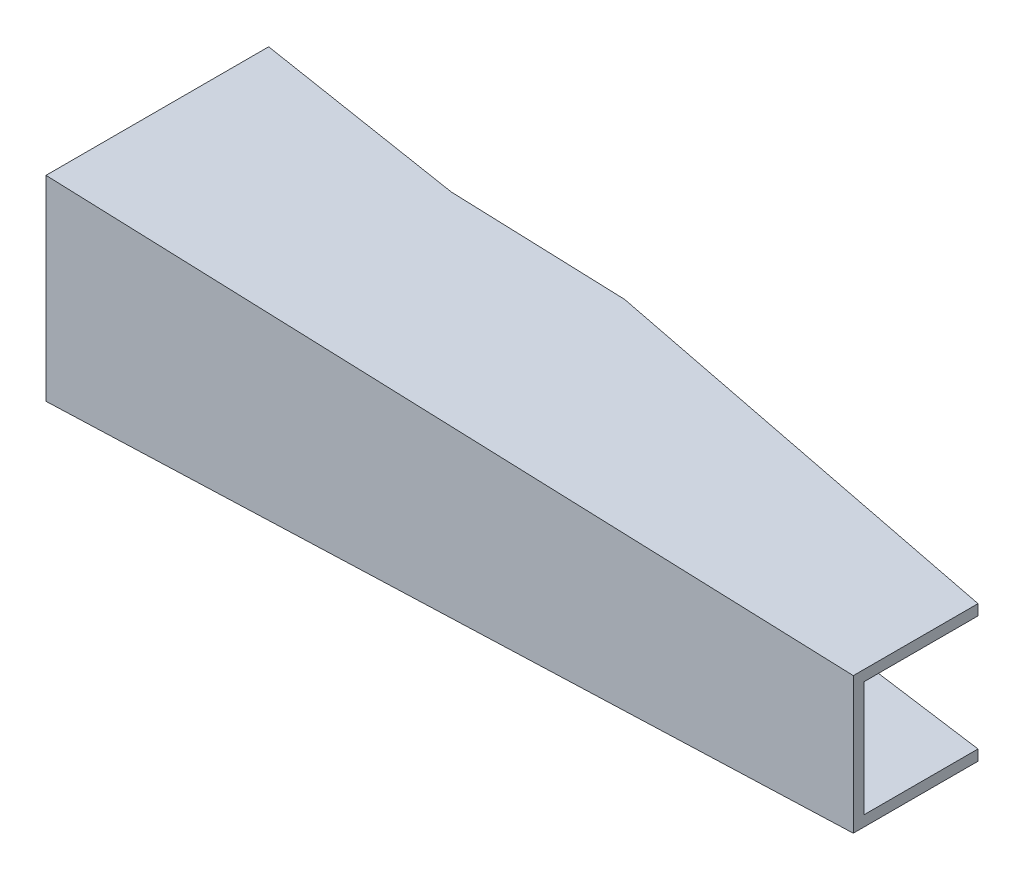
from build123d import *

# Parameters (mm, degrees)
BOSS_EXTRUDE1_DEPTH     = 105
CUT_EXTRUDE1_DEPTH      = 105.1
CUT_EXTRUDE1_DEPTH_BACK = 105.1
SKETCH4_W               = 78.145475997
SKETCH4_H               = 46.57
SKETCH5_W               = 111.656527507
SKETCH5_H               = 70.51


with BuildPart() as part:
    # Sketch1 → Boss-Extrude1 (new body)
    with BuildSketch(Plane.XY):
        Polygon((0, 39.555), (0, -39.555), (326.3, -27.585), (326.3, 27.585), align=None)
    extrude(amount=BOSS_EXTRUDE1_DEPTH)

    # Sketch3 → Cut-Extrude1 (cut, two sides)
    with BuildSketch(Plane(origin=(0, 0, 0), x_dir=(1, 0, 0), z_dir=(0, 1, 0))) as cut_extrude1_sk:
        Polygon((0, -15), (84.7, -25.82), (154.7, -25.82), (326.3, -54.6), (326.3, 36.079011671), (0, 41.113860107), align=None)
    extrude(amount=CUT_EXTRUDE1_DEPTH, mode=Mode.SUBTRACT)
    extrude(cut_extrude1_sk.sketch, amount=-CUT_EXTRUDE1_DEPTH_BACK, mode=Mode.SUBTRACT)

    # Sketch4 → Cut-Loft1 section 0
    with BuildSketch(Plane(origin=(326.3, 0, 0), x_dir=(0, 0, -1), z_dir=(1, 0, 0))):
        with Locations((-61.627262002, 0)):
            Rectangle(SKETCH4_W, SKETCH4_H)
    # Sketch5 → Cut-Loft1 section 1
    with BuildSketch(Plane.ZY):
        with Locations((44.871736246, 0)):
            Rectangle(SKETCH5_W, SKETCH5_H)
    loft(mode=Mode.SUBTRACT)


solid = part.part
